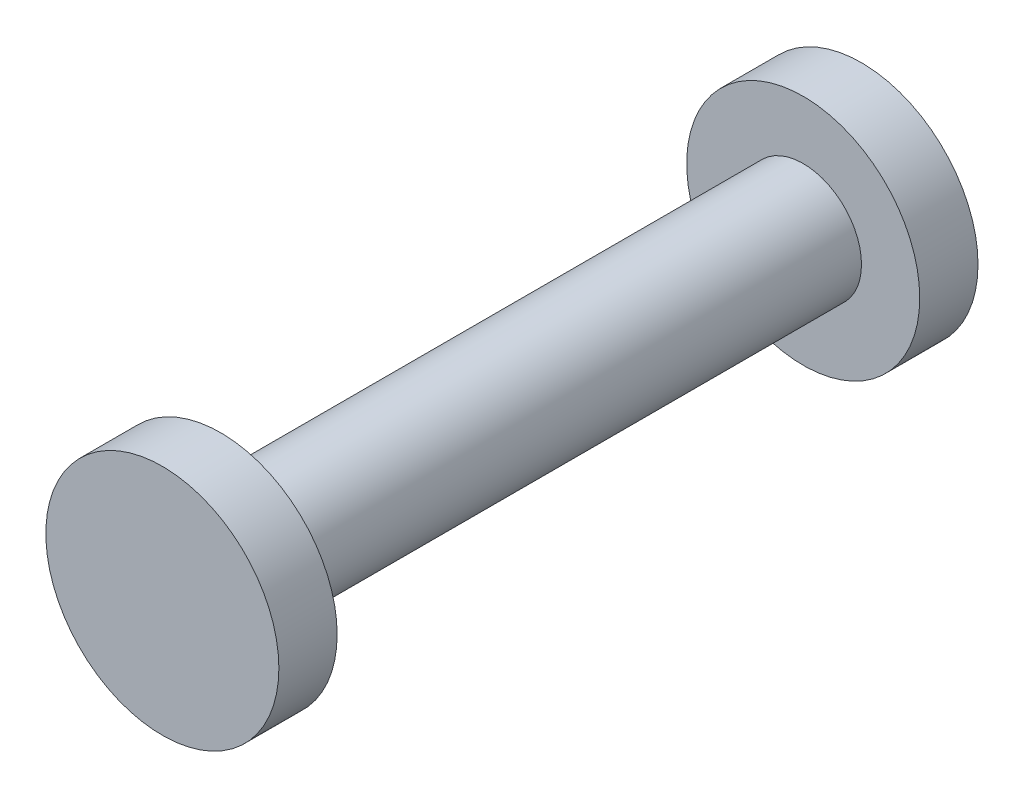
from build123d import *

# Parameters (mm, degrees)
SKETCH1_R           = 5
BOSS_EXTRUDE1_DEPTH = 25
SKETCH2_R           = 10
BOSS_EXTRUDE2_DEPTH = 5


with BuildPart() as part:
    # Sketch1 → Boss-Extrude1 (new body, symmetric)
    with BuildSketch(Plane.XY):
        Circle(SKETCH1_R)
    extrude(amount=BOSS_EXTRUDE1_DEPTH, both=True)

    # Sketch2 → Boss-Extrude2 (add)
    with BuildSketch(Plane.XY.offset(25)):
        Circle(SKETCH2_R)
    boss_extrude2 = extrude(amount=BOSS_EXTRUDE2_DEPTH)

    # Mirror1: Boss-Extrude2 across plane
    add(boss_extrude2.mirror(Plane.XY))


solid = part.part
